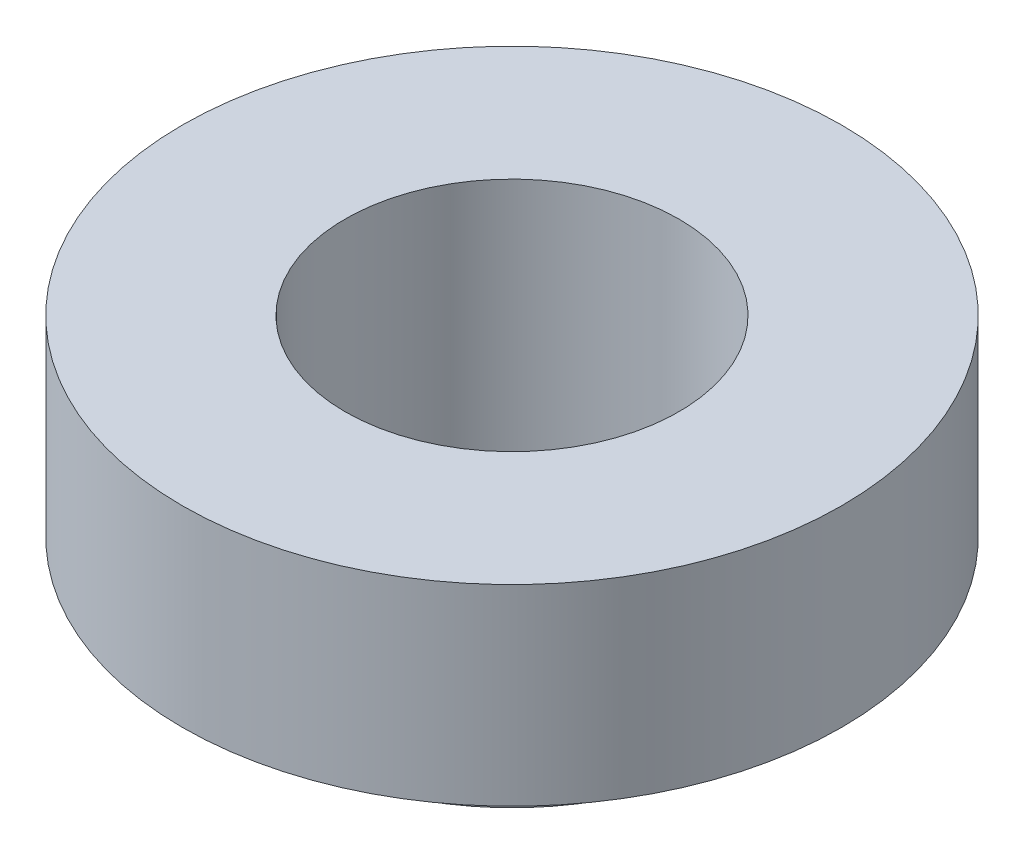
from build123d import *

# Parameters (mm, degrees)
SKETCH_1_R          = 3.95
EXTRUDE_1_DEPTH     = 2.3
SKETCH_3_R          = 2.7
EXTRUDE_2_DEPTH     = 0.9
SKETCH_4_R          = 2
CUT_EXTRUDE_1_DEPTH = 3.3


with BuildPart() as part:
    # ｽｹｯﾁ1 → ﾎﾞｽ - 押し出し1 (new body)
    with BuildSketch(Plane(origin=(0, 0, 0), x_dir=(1, 0, 0), z_dir=(0, 1, 0))):
        Circle(SKETCH_1_R)
    extrude(amount=EXTRUDE_1_DEPTH)

    # ｽｹｯﾁ3 → ﾎﾞｽ - 押し出し2 (add)
    with BuildSketch(Plane(origin=(0, 0, 0), x_dir=(-1, 0, 0), z_dir=(0, -1, 0))):
        Circle(SKETCH_3_R)
    extrude(amount=EXTRUDE_2_DEPTH)

    # ｽｹｯﾁ4 → ｶｯﾄ - 押し出し1 (cut)
    with BuildSketch(Plane(origin=(0, -0.9, 0), x_dir=(-1, 0, 0), z_dir=(0, -1, 0))):
        Circle(SKETCH_4_R)
    extrude(amount=-CUT_EXTRUDE_1_DEPTH, mode=Mode.SUBTRACT)


solid = part.part
